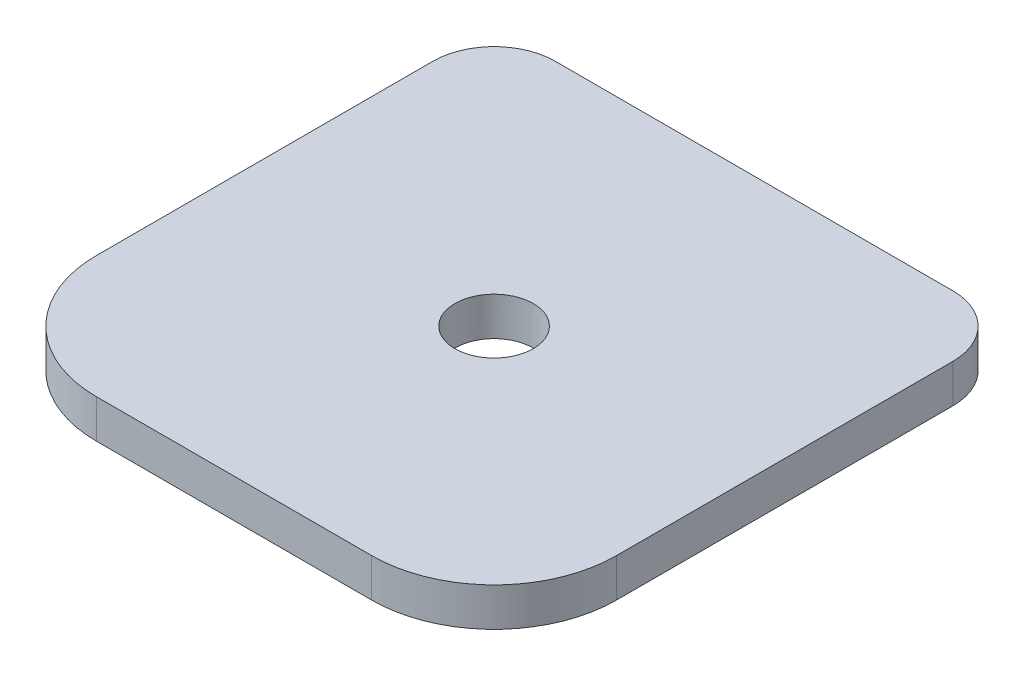
from build123d import *

# Parameters (mm, degrees)
SKETCH1_W           = 85
SKETCH1_H           = 85
BOSS_EXTRUDE1_DEPTH = 6.3
CUT_EXTRUDE1_REACH  = 8.3
SKETCH2_R           = 6.4
FILLET1_R           = 10
FILLET2_R           = 20


with BuildPart() as part:
    # Sketch1 → Boss-Extrude1 (new body)
    with BuildSketch(Plane(origin=(0, 0, 0), x_dir=(1, 0, 0), z_dir=(0, 1, 0))):
        with Locations((42.5, 42.5)):
            Rectangle(SKETCH1_W, SKETCH1_H)
    extrude(amount=BOSS_EXTRUDE1_DEPTH)

    # Sketch2 → Cut-Extrude1 (cut, up to next)
    with BuildSketch(Plane(origin=(0, 6.3, 0), x_dir=(1, 0, 0), z_dir=(0, 1, 0)), mode=Mode.PRIVATE) as cut_extrude1_sk1:
        with Locations((42.5, 42.5)):
            Circle(SKETCH2_R)
    cut_extrude1_tool1 = extrude(cut_extrude1_sk1.sketch, amount=-CUT_EXTRUDE1_REACH, mode=Mode.PRIVATE) & part.part
    add(cut_extrude1_tool1.solids().sort_by_distance((42.5, 6.3, -42.5))[0], mode=Mode.SUBTRACT)

    # Fillet1
    fillet1_edges = [part.edges().sort_by_distance(p)[0] for p in [
        (0, 3.15, -85),
        (85, 3.15, -85),
    ]]
    fillet(fillet1_edges, radius=FILLET1_R)

    # Fillet2
    fillet2_edges = [part.edges().sort_by_distance(p)[0] for p in [
        (85, 3.15, 0),
        (0, 3.15, 0),
    ]]
    fillet(fillet2_edges, radius=FILLET2_R)


solid = part.part
